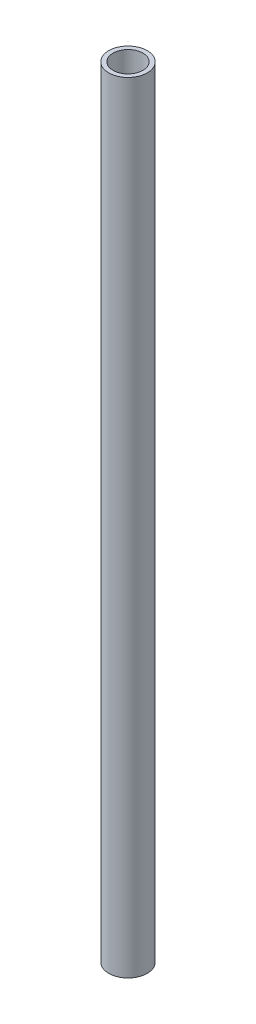
from build123d import *

# Parameters (mm, degrees)
SKETCH1_R           = 57
BOSS_EXTRUDE1_DEPTH = 2307.62
SHELL1_T            = -12.7


with BuildPart() as part:
    # Sketch1 → Boss-Extrude1 (new body)
    with BuildSketch(Plane(origin=(0, 0, 0), x_dir=(1, 0, 0), z_dir=(0, 1, 0))):
        with Locations(Location((0, 0, 0), (0, 0, 270))):
            Circle(SKETCH1_R)
    extrude(amount=BOSS_EXTRUDE1_DEPTH)

    # Shell1
    shell1_openings = [part.faces().sort_by_distance(p)[0] for p in [
        (0, 2307.62, 0),
    ]]
    offset(amount=SHELL1_T, openings=shell1_openings, kind=Kind.INTERSECTION)


solid = part.part
